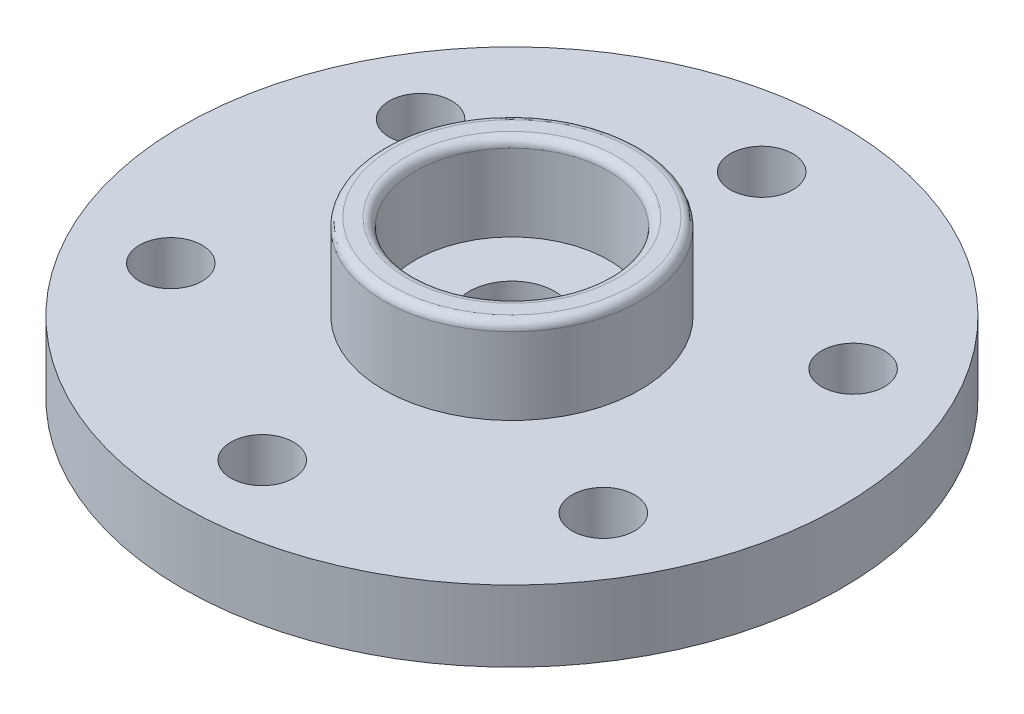
from build123d import *

# Parameters (mm, degrees)
CROQUIS1_R              = 11.575
SALIENTE_EXTRUIR1_DEPTH = 2.5
CROQUIS2_R              = 4.5
CROQUIS2_R_2            = 3.4
SALIENTE_EXTRUIR2_DEPTH = 3
CORTAR_EXTRUIR1_REACH   = 7.5
CROQUIS3_R              = 1.5
CROQUIS4_R              = 2.8
CORTAR_EXTRUIR2_DEPTH   = 1
CROQUIS5_R              = 4.5
CROQUIS5_R_2            = 3.5
CORTAR_EXTRUIR3_DEPTH   = 0.5
REDONDEO1_R             = 0.3
CROQUIS6_R              = 1.1
CORTAR_EXTRUIR4_DEPTH   = 2.5
MATRIZC1_COUNT          = 6


with BuildPart() as part:
    # Croquis1 → Saliente-Extruir1 (new body)
    with BuildSketch(Plane(origin=(0, 0, 0), x_dir=(1, 0, 0), z_dir=(0, 1, 0))):
        Circle(CROQUIS1_R)
    extrude(amount=SALIENTE_EXTRUIR1_DEPTH)

    # Croquis2 → Saliente-Extruir2 (add)
    with BuildSketch(Plane(origin=(0, 2.5, 0), x_dir=(1, 0, 0), z_dir=(0, 1, 0))):
        Circle(CROQUIS2_R)
        Circle(CROQUIS2_R_2, mode=Mode.SUBTRACT)
    extrude(amount=SALIENTE_EXTRUIR2_DEPTH)

    # Croquis3 → Cortar-Extruir1 (cut, up to next)
    with BuildSketch(Plane.XZ, mode=Mode.PRIVATE) as cortar_extruir1_sk1:
        Circle(CROQUIS3_R)
    cortar_extruir1_tool1 = extrude(cortar_extruir1_sk1.sketch, amount=-CORTAR_EXTRUIR1_REACH, mode=Mode.PRIVATE) & part.part
    add(cortar_extruir1_tool1.solids().sort_by_distance((0, 0, 0))[0], mode=Mode.SUBTRACT)

    # Croquis4 → Cortar-Extruir2 (cut)
    with BuildSketch(Plane.XZ):
        Circle(CROQUIS4_R)
    extrude(amount=-CORTAR_EXTRUIR2_DEPTH, mode=Mode.SUBTRACT)

    # Croquis5 → Cortar-Extruir3 (cut)
    with BuildSketch(Plane.XZ):
        Circle(CROQUIS5_R)
        Circle(CROQUIS5_R_2, mode=Mode.SUBTRACT)
    extrude(amount=-CORTAR_EXTRUIR3_DEPTH, mode=Mode.SUBTRACT)

    # Redondeo1
    redondeo1_edges = [part.edges().sort_by_distance(p)[0] for p in [
        (-2.8, 0, 0),
        (-4.5, 0, 0),
        (-3.5, 0, 0),
        (-4.5, 5.5, 0),
        (-3.4, 5.5, 0),
    ]]
    fillet(redondeo1_edges, radius=REDONDEO1_R)

    # Croquis6 → Cortar-Extruir4 (cut)
    with BuildSketch(Plane.XZ):
        with Locations((0, -8.771)):
            Circle(CROQUIS6_R)
    cortar_extruir4 = extrude(amount=-CORTAR_EXTRUIR4_DEPTH, mode=Mode.SUBTRACT)

    # MatrizC1: Cortar-Extruir4 ×6 about axis
    matrizc1_axis = Axis((0, 0, 0), (0, 1, 0))
    for i in range(1, MATRIZC1_COUNT):
        add(cortar_extruir4.rotate(matrizc1_axis, i * 360 / MATRIZC1_COUNT), mode=Mode.SUBTRACT)


solid = part.part
